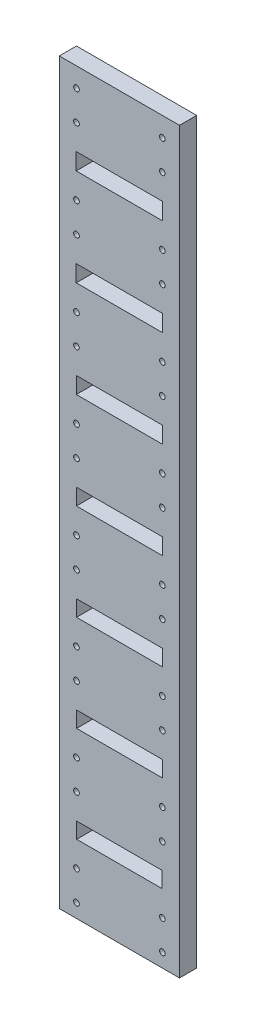
from build123d import *

# Parameters (mm, degrees)
SKETCH1_W           = 70
SKETCH1_H           = 430
SKETCH1_W_2         = 50.4
SKETCH1_H_2         = 9.8
SKETCH1_W_3         = 49.8
SKETCH1_H_3         = 9.2
SKETCH1_W_4         = 49.9
SKETCH1_H_4         = 9.3
SKETCH1_W_5         = 50
SKETCH1_H_5         = 9.4
SKETCH1_W_6         = 50.1
SKETCH1_H_6         = 9.5
SKETCH1_W_7         = 50.2
SKETCH1_H_7         = 9.6
SKETCH1_W_8         = 50.3
SKETCH1_H_8         = 9.7
BOSS_EXTRUDE1_DEPTH = 10
M4_TAPPED_HOLE1_D   = 3.3


with BuildPart() as part:
    # Sketch1 → Boss-Extrude1 (new body)
    with BuildSketch(Plane.XY):
        Rectangle(SKETCH1_W, SKETCH1_H)
        with Locations((0, 166.8)):
            Rectangle(SKETCH1_W_2, SKETCH1_H_2, mode=Mode.SUBTRACT)
        with Locations((0, -170.4)):
            Rectangle(SKETCH1_W_3, SKETCH1_H_3, mode=Mode.SUBTRACT)
        with Locations((0, -114.45)):
            Rectangle(SKETCH1_W_4, SKETCH1_H_4, mode=Mode.SUBTRACT)
        with Locations((0, -58.4)):
            Rectangle(SKETCH1_W_5, SKETCH1_H_5, mode=Mode.SUBTRACT)
        with Locations((0, -2.25)):
            Rectangle(SKETCH1_W_6, SKETCH1_H_6, mode=Mode.SUBTRACT)
        with Locations((0, 54)):
            Rectangle(SKETCH1_W_7, SKETCH1_H_7, mode=Mode.SUBTRACT)
        with Locations((0, 110.35)):
            Rectangle(SKETCH1_W_8, SKETCH1_H_8, mode=Mode.SUBTRACT)
    extrude(amount=BOSS_EXTRUDE1_DEPTH)

    # M4 Tapped Hole1 (through all)
    with Locations(Plane.XY.offset(10)):
        with Locations((-25, -189.7), (25, -189.7), (25, -207), (-25, -207), (-25, -133.8), (25, -133.8), (25, -151.1), (-25, -151.1), (-25, -77.8), (25, -77.8), (25, -95.1), (-25, -95.1), (-25, -21.7), (25, -21.7), (25, -39), (-25, -39), (-25, 34.5), (25, 34.5), (25, 17.2), (-25, 17.2), (-25, 90.8), (25, 90.8), (25, 73.5), (-25, 73.5), (-25, 147.2), (25, 147.2), (25, 129.9), (-25, 129.9), (-25, 203.7), (25, 203.7), (25, 186.4), (-25, 186.4)):
            Hole(M4_TAPPED_HOLE1_D / 2)


solid = part.part
